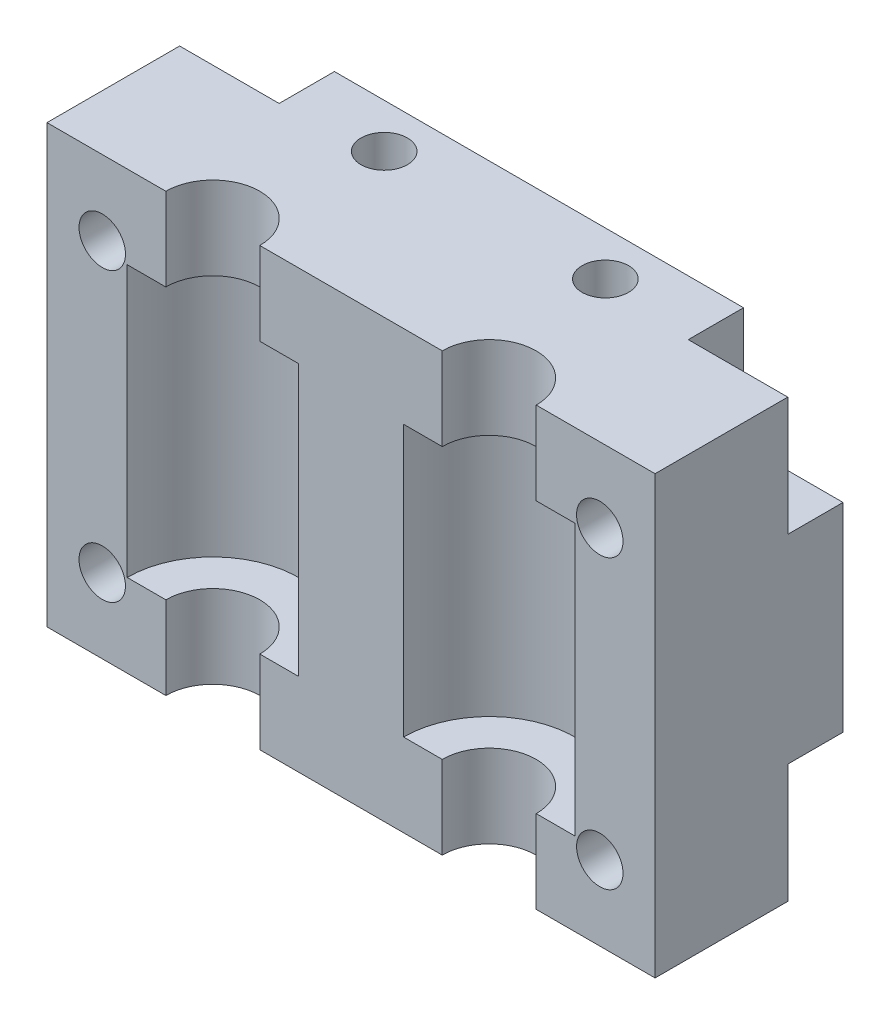
from build123d import *

# Parameters (mm, degrees)
ESQUISSE1_W             = 55
ESQUISSE1_H             = 45
BOSS_EXTRU_1_DEPTH      = 12
ESQUISSE2_R             = 4.25
ENL_V_MAT_EXTRU_1_DEPTH = 46
ESQUISSE3_R             = 7.75
ENL_V_MAT_EXTRU_2_DEPTH = 12.25
ESQUISSE9_W             = 61.062756781
ESQUISSE9_H             = 12.22812859
ESQUISSE9_W_2           = 59.427147224
ESQUISSE9_H_2           = 8.100161614
ENL_V_MAT_EXTRU_7_DEPTH = 31
SKETCH1_W               = 55
SKETCH1_H               = 36
BOSS_EXTRUDE1_DEPTH     = 5
SKETCH2_R               = 2.1
CUT_EXTRUDE1_DEPTH      = 18
SKETCH3_R               = 4
CUT_EXTRUDE2_DEPTH      = 10
CUT_EXTRUDE3_DEPTH      = 5
SKETCH5_R               = 2.1
CUT_EXTRUDE4_DEPTH      = 37
SKETCH7_R               = 2.1
BOSS_EXTRUDE4_DEPTH     = 2
SKETCH8_R               = 2.1
BOSS_EXTRUDE5_DEPTH     = 2
SKETCH9_W               = 7
SKETCH9_H               = 3.2
CUT_EXTRUDE6_DEPTH      = 8
CUT_EXTRUDE7_DEPTH      = 0.25
CUT_EXTRUDE8_DEPTH      = 0.25


with BuildPart() as part:
    # Esquisse1 → Boss.-Extru.1 (new body)
    with BuildSketch(Plane.XY):
        Rectangle(ESQUISSE1_W, ESQUISSE1_H)
    extrude(amount=BOSS_EXTRU_1_DEPTH)

    # Esquisse2 → Enlèv. mat.-Extru.1 (cut, through all)
    with BuildSketch(Plane(origin=(0, 22.5, 0), x_dir=(1, 0, 0), z_dir=(0, 1, 0))):
        with Locations((-12.5, -12)):
            Circle(ESQUISSE2_R)
        with Locations((12.5, -12)):
            Circle(ESQUISSE2_R)
    extrude(amount=-ENL_V_MAT_EXTRU_1_DEPTH, mode=Mode.SUBTRACT)

    # Esquisse3 → Enlèv. mat.-Extru.2 (cut, symmetric)
    with BuildSketch(Plane(origin=(0, 0, 0), x_dir=(1, 0, 0), z_dir=(0, 1, 0))):
        with Locations((-12.5, -12)):
            Circle(ESQUISSE3_R)
    enl_v_mat_extru_2 = extrude(amount=ENL_V_MAT_EXTRU_2_DEPTH, both=True, mode=Mode.SUBTRACT)

    # Esquisse9 → Enlèv. mat.-Extru.7 (cut)
    with BuildSketch(Plane.XY.offset(12)):
        with Locations((-0.389430846, -24.114064295)):
            Rectangle(ESQUISSE9_W, ESQUISSE9_H)
        with Locations((1.674552641, 22.050080807)):
            Rectangle(ESQUISSE9_W_2, ESQUISSE9_H_2)
    extrude(amount=-ENL_V_MAT_EXTRU_7_DEPTH, mode=Mode.SUBTRACT)

    # Sketch1 → Boss-Extrude1 (add)
    with BuildSketch(Plane(origin=(0, 0, 0), x_dir=(-1, 0, 0), z_dir=(0, 0, -1))):
        Rectangle(SKETCH1_W, SKETCH1_H)
    extrude(amount=BOSS_EXTRUDE1_DEPTH)

    # Sketch2 → Cut-Extrude1 (cut, through all)
    with BuildSketch(Plane.XY.offset(12)):
        with Locations((-22.5, 13)):
            Circle(SKETCH2_R)
        with Locations((22.5, 13)):
            Circle(SKETCH2_R)
        with Locations((22.5, -13)):
            Circle(SKETCH2_R)
        with Locations((-22.5, -13)):
            Circle(SKETCH2_R)
    extrude(amount=-CUT_EXTRUDE1_DEPTH, mode=Mode.SUBTRACT)

    # Sketch3 → Cut-Extrude2 (cut)
    with BuildSketch(Plane(origin=(0, 0, -5), x_dir=(-1, 0, 0), z_dir=(0, 0, -1))):
        with Locations((-22.5, 13)):
            Circle(SKETCH3_R)
        with Locations((22.5, 13)):
            Circle(SKETCH3_R)
        with Locations((22.5, -13)):
            Circle(SKETCH3_R)
        with Locations((-22.5, -13)):
            Circle(SKETCH3_R)
    extrude(amount=-CUT_EXTRUDE2_DEPTH, mode=Mode.SUBTRACT)

    # Sketch4 → Cut-Extrude3 (cut)
    with BuildSketch(Plane(origin=(0, 0, -5), x_dir=(-1, 0, 0), z_dir=(0, 0, -1))):
        with BuildLine():
            Line((-18.5, 13), (-18.5, 18))
            Line((-18.5, 18), (-27.5, 18))
            Line((-27.5, 18), (-27.5, 9))
            Line((-27.5, 9), (-22.5, 9))
            ThreePointArc((-22.5, 9), (-25.328427125, 15.828427125), (-18.5, 13))
        make_face()
        with BuildLine():
            Line((-22.5, -9), (-27.5, -9))
            Line((-27.5, -9), (-27.5, -18))
            Line((-27.5, -18), (-18.5, -18))
            Line((-18.5, -18), (-18.5, -13))
            ThreePointArc((-18.5, -13), (-25.328427125, -15.828427125), (-22.5, -9))
        make_face()
        with BuildLine():
            Line((27.5, -18), (27.5, -9))
            Line((27.5, -9), (22.5, -9))
            ThreePointArc((22.5, -9), (25.328427125, -15.828427125), (18.5, -13))
            Line((18.5, -13), (18.5, -18))
            Line((18.5, -18), (27.5, -18))
        make_face()
        with BuildLine():
            Line((27.5, 18), (18.5, 18))
            Line((18.5, 18), (18.5, 13))
            ThreePointArc((18.5, 13), (25.328427125, 15.828427125), (22.5, 9))
            Line((22.5, 9), (27.5, 9))
            Line((27.5, 9), (27.5, 18))
        make_face()
    extrude(amount=-CUT_EXTRUDE3_DEPTH, mode=Mode.SUBTRACT)

    # Sketch5 → Cut-Extrude4 (cut, through all)
    with BuildSketch(Plane(origin=(0, 18, 0), x_dir=(1, 0, 0), z_dir=(0, 1, 0))):
        with Locations((-10, 1)):
            Circle(SKETCH5_R)
        with Locations((10, 1)):
            Circle(SKETCH5_R)
    extrude(amount=-CUT_EXTRUDE4_DEPTH, mode=Mode.SUBTRACT)

    # Sketch7 → Boss-Extrude4 (add)
    with BuildSketch(Plane(origin=(0, 18, 0), x_dir=(1, 0, 0), z_dir=(0, 1, 0))):
        with BuildLine():
            Line((18.5, 5), (-18.5, 5))
            Line((-18.5, 5), (-18.5, 0))
            Line((-18.5, 0), (-27.5, 0))
            Line((-27.5, 0), (-27.5, -12))
            Line((-27.5, -12), (-16.75, -12))
            ThreePointArc((-16.75, -12), (-12.5, -7.75), (-8.25, -12))
            Line((-8.25, -12), (8.25, -12))
            ThreePointArc((8.25, -12), (12.5, -7.75), (16.75, -12))
            Line((16.75, -12), (27.5, -12))
            Line((27.5, -12), (27.5, 0))
            Line((27.5, 0), (18.5, 0))
            Line((18.5, 0), (18.5, 5))
        make_face()
        with Locations((10, 1)):
            Circle(SKETCH7_R, mode=Mode.SUBTRACT)
        with Locations((-10, 1)):
            Circle(SKETCH7_R, mode=Mode.SUBTRACT)
    extrude(amount=BOSS_EXTRUDE4_DEPTH)

    # Sketch8 → Boss-Extrude5 (add)
    with BuildSketch(Plane.XZ.offset(18)):
        with BuildLine():
            Line((-27.5, 0), (-18.5, 0))
            Line((-18.5, 0), (-18.5, -5))
            Line((-18.5, -5), (18.5, -5))
            Line((18.5, -5), (18.5, 0))
            Line((18.5, 0), (27.5, 0))
            Line((27.5, 0), (27.5, 12))
            Line((27.5, 12), (16.75, 12))
            ThreePointArc((16.75, 12), (12.5, 7.75), (8.25, 12))
            Line((8.25, 12), (-8.25, 12))
            ThreePointArc((-8.25, 12), (-12.5, 7.75), (-16.75, 12))
            Line((-16.75, 12), (-27.5, 12))
            Line((-27.5, 12), (-27.5, 0))
        make_face()
        with Locations((10, -1)):
            Circle(SKETCH8_R, mode=Mode.SUBTRACT)
        with Locations((-10, -1)):
            Circle(SKETCH8_R, mode=Mode.SUBTRACT)
    extrude(amount=BOSS_EXTRUDE5_DEPTH)

    # Sketch9 → Cut-Extrude6 (cut)
    with BuildSketch(Plane(origin=(0, 0, -5), x_dir=(-1, 0, 0), z_dir=(0, 0, -1))):
        with Locations((-10, 14.4)):
            Rectangle(SKETCH9_W, SKETCH9_H)
        with Locations((10, 14.4)):
            Rectangle(SKETCH9_W, SKETCH9_H)
        with Locations((10, -14.4)):
            Rectangle(SKETCH9_W, SKETCH9_H)
        with Locations((-10, -14.4)):
            Rectangle(SKETCH9_W, SKETCH9_H)
    extrude(amount=-CUT_EXTRUDE6_DEPTH, mode=Mode.SUBTRACT)

    # Mirror1: Enlèv. mat.-Extru.2 across plane
    add(enl_v_mat_extru_2.mirror(Plane.ZY), mode=Mode.SUBTRACT)

    # Sketch10 → Cut-Extrude7 (cut)
    with BuildSketch(Plane.XZ.offset(20)):
        with BuildLine():
            Line((-27.5, 12), (-27.5, 0))
            Line((-27.5, 0), (-18.5, 0))
            Line((-18.5, 0), (-18.5, -5))
            Line((-18.5, -5), (18.5, -5))
            Line((18.5, -5), (18.5, 0))
            Line((18.5, 0), (27.5, 0))
            Line((27.5, 0), (27.5, 12))
            Line((27.5, 12), (16.75, 12))
            ThreePointArc((16.75, 12), (12.5, 7.75), (8.25, 12))
            Line((8.25, 12), (-8.25, 12))
            ThreePointArc((-8.25, 12), (-12.5, 7.75), (-16.75, 12))
            Line((-16.75, 12), (-27.5, 12))
        make_face()
    extrude(amount=-CUT_EXTRUDE7_DEPTH, mode=Mode.SUBTRACT)

    # Sketch11 → Cut-Extrude8 (cut)
    with BuildSketch(Plane(origin=(0, 20, 0), x_dir=(1, 0, 0), z_dir=(0, 1, 0))):
        with BuildLine():
            Line((18.5, 0), (18.5, 5))
            Line((18.5, 5), (-18.5, 5))
            Line((-18.5, 5), (-18.5, 0))
            Line((-18.5, 0), (-27.5, 0))
            Line((-27.5, 0), (-27.5, -12))
            Line((-27.5, -12), (-16.75, -12))
            ThreePointArc((-16.75, -12), (-12.5, -7.75), (-8.25, -12))
            Line((-8.25, -12), (8.25, -12))
            ThreePointArc((8.25, -12), (12.5, -7.75), (16.75, -12))
            Line((16.75, -12), (27.5, -12))
            Line((27.5, -12), (27.5, 0))
            Line((27.5, 0), (18.5, 0))
        make_face()
    extrude(amount=-CUT_EXTRUDE8_DEPTH, mode=Mode.SUBTRACT)


solid = part.part
